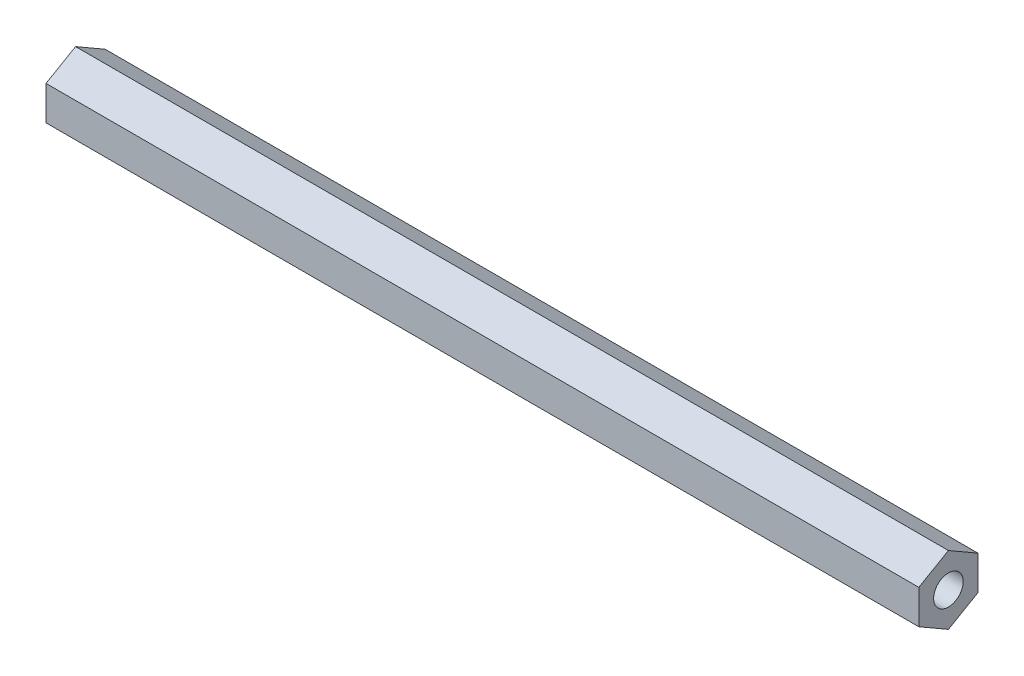
from build123d import *

# Parameters (mm, degrees)
SKETCH1_R           = 3.175
BOSS_EXTRUDE1_DEPTH = 187.325


with BuildPart() as part:
    # Sketch1 → Boss-Extrude1 (new body)
    with BuildSketch(Plane(origin=(0, 0, 0), x_dir=(0, 0, -1), z_dir=(1, 0, 0))):
        Polygon((0, 7.332348419), (-6.35, 3.666174209), (-6.35, -3.666174209), (0, -7.332348419), (6.35, -3.666174209), (6.35, 3.666174209), align=None)
        Circle(SKETCH1_R, mode=Mode.SUBTRACT)
    extrude(amount=BOSS_EXTRUDE1_DEPTH)


solid = part.part
